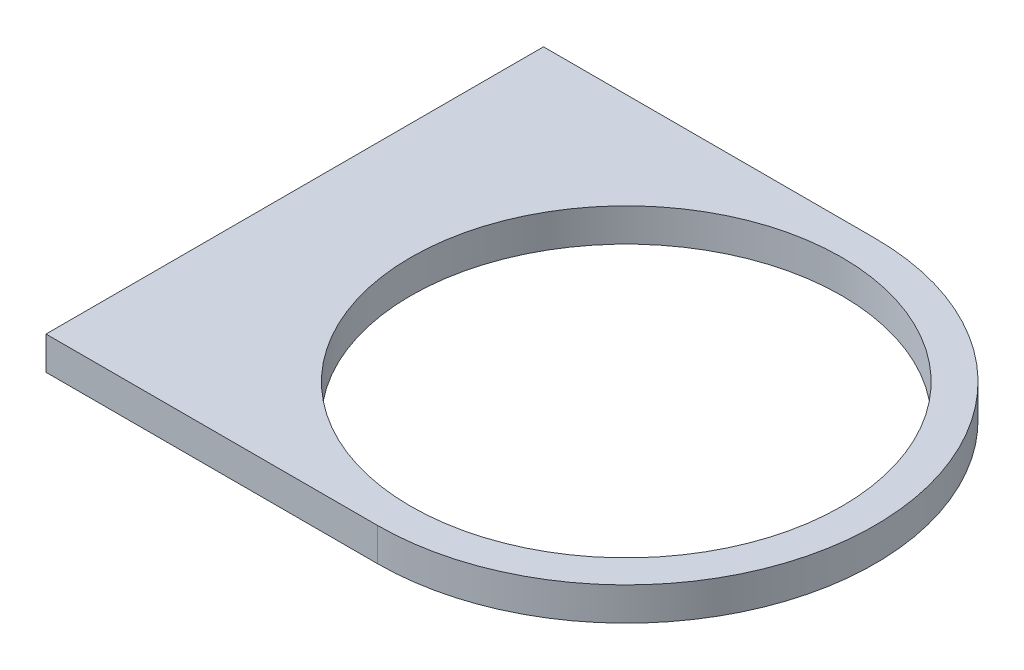
from build123d import *

# Parameters (mm, degrees)
SKETCH2_W           = 111.10281597
SKETCH2_H           = 6.35
BOSS_EXTRUDE1_DEPTH = 95.25
SKETCH3_R           = 41.275
CUT_EXTRUDE2_DEPTH  = 7.35
CUT_EXTRUDE3_DEPTH  = 7.35


with BuildPart() as part:
    # Sketch2 → Boss-Extrude1 (new body)
    with BuildSketch(Plane.XY):
        with Locations((100.171199764, 3.175)):
            Rectangle(SKETCH2_W, SKETCH2_H)
    extrude(amount=BOSS_EXTRUDE1_DEPTH)

    # Sketch3 → Cut-Extrude2 (cut, through all)
    with BuildSketch(Plane(origin=(0, 6.35, 0), x_dir=(1, 0, 0), z_dir=(0, 1, 0))):
        with Locations((108.097607749, -47.625)):
            Circle(SKETCH3_R)
    extrude(amount=-CUT_EXTRUDE2_DEPTH, mode=Mode.SUBTRACT)

    # Sketch4 → Cut-Extrude3 (cut, through all)
    with BuildSketch(Plane(origin=(0, 6.35, 0), x_dir=(1, 0, 0), z_dir=(0, 1, 0))):
        with BuildLine():
            Line((108.097607749, -95.25), (179.051442703, -95.25))
            Line((179.051442703, -95.25), (179.051442703, 0))
            Line((179.051442703, 0), (108.097607749, 0))
            ThreePointArc((108.097607749, 0), (155.722607749, -47.625), (108.097607749, -95.25))
        make_face()
    extrude(amount=-CUT_EXTRUDE3_DEPTH, mode=Mode.SUBTRACT)


solid = part.part
